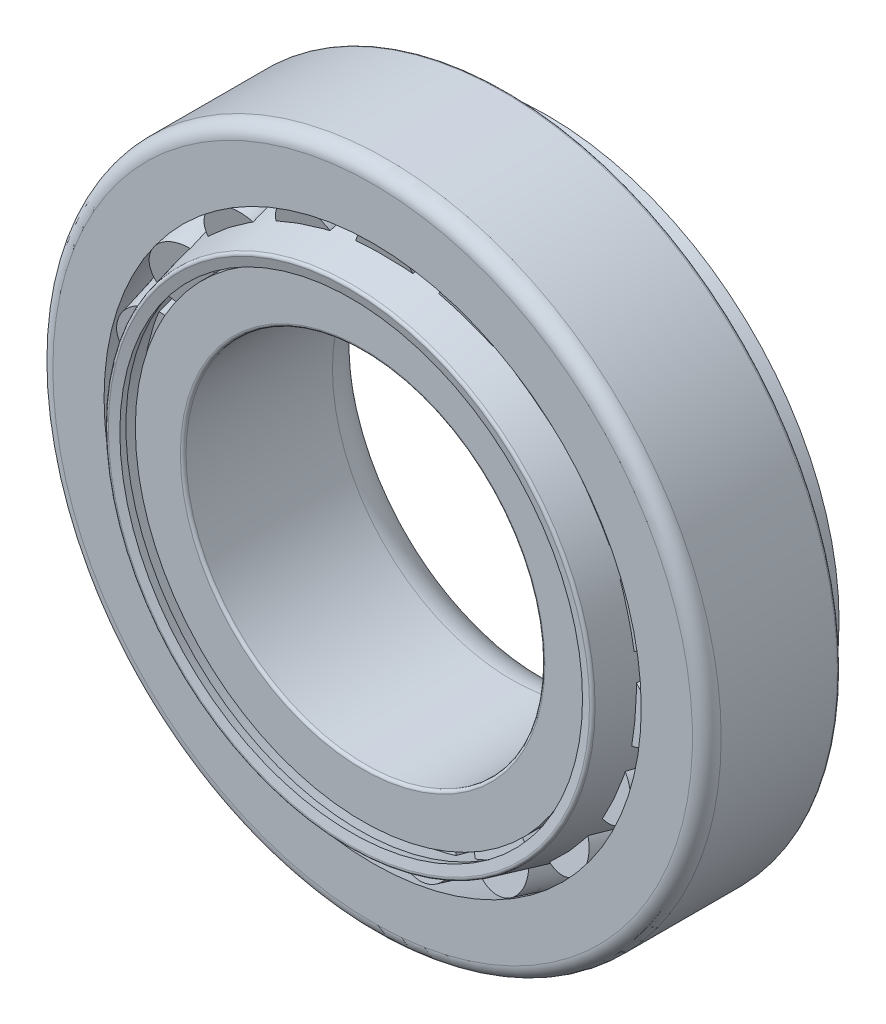
from build123d import *

# Parameters (mm, degrees)
CIRPATTERN1_COUNT = 19
FILLET1_R         = 3.556
FILLET2_R         = 1.27
FILLET3_R         = 0.254
FILLET4_R         = 0.254
FILLET5_R         = 0.254


with BuildPart() as part:
    # Sketch2 → Revolve1 (revolve)
    with BuildSketch(Plane(origin=(0, 0, 0), x_dir=(0, 0, -1), z_dir=(1, 0, 0))):
        Polygon((-5.9055, 29.5671875), (-5.9055, 23.765), (5.9055, 27.015), (5.9055, 29.5671875), align=None)
    revolve(axis=Axis((0, 0, 0), (0, 0, -1)))

    # Fillet2
    fillet2_edges = [part.edges().sort_by_distance(p)[0] for p in [
        (0, -29.5671875, 5.9055),
    ]]
    fillet(fillet2_edges, radius=FILLET2_R)

    # Fillet4
    fillet4_edges = [part.edges().sort_by_distance(p)[0] for p in [
        (0, -29.5671875, -5.9055),
    ]]
    fillet(fillet4_edges, radius=FILLET4_R)


with BuildPart() as body_2:
    # Sketch3 → Revolve2 (revolve)
    with BuildSketch(Plane(origin=(0, 0, 0), x_dir=(0, 0, -1), z_dir=(1, 0, 0))):
        Polygon((-6.7945, 20.11), (-6.7945, 15.875), (9.9695, 15.875), (9.9695, 22.59), (6.332558027, 22.59), (6.706097905, 21.056484436), (-4.038892795, 18.773679177), (-4.364399187, 20.11), align=None)
    revolve(axis=Axis((0, 0, 0), (0, 0, -1)))

    # Fillet1
    fillet1_edges = [body_2.edges().sort_by_distance(p)[0] for p in [
        (0, -15.875, -9.9695),
    ]]
    fillet(fillet1_edges, radius=FILLET1_R)

    # Fillet3
    fillet3_edges = [body_2.edges().sort_by_distance(p)[0] for p in [
        (0, -15.875, 6.7945),
    ]]
    fillet(fillet3_edges, radius=FILLET3_R)


with BuildPart() as body_3:
    # Sketch4 → Revolve3 (revolve)
    with BuildSketch(Plane(origin=(0, 0, 0), x_dir=(0, 0, -1), z_dir=(1, 0, 0))):
        Polygon((9.7155, 25.113969057), (9.542735161, 25.823230864), (-8.0645, 21.534389832), (-7.805352742, 20.470497121), (-7.096090935, 20.64326196), (-7.182473355, 20.997892863), align=None)
    revolve(axis=Axis((0, 0, 0), (0, 0, -1)))

    # Fillet5
    fillet5_edges = [body_3.edges().sort_by_distance(p)[0] for p in [
        (0, -21.534389832, 8.0645),
    ]]
    fillet(fillet5_edges, radius=FILLET5_R)


with BuildPart() as body_4:
    # Sketch6 → Revolve4 (revolve)
    with BuildSketch(Plane(origin=(0, 0, 0), x_dir=(0, 0, -1), z_dir=(1, 0, 0))):
        Polygon((6.706097905, 21.056484436), (6.000838701, 23.951827155), (-4.667236146, 21.353254652), (-4.038892795, 18.773679177), align=None)
    revolve(axis=Axis((0, 21.353254652, 4.667236146), (0, 0.236664162, -0.971591516)))


with BuildPart() as cirpattern1_1:
    # CirPattern1: pattern copy
    add(body_4.part.rotate(Axis((0, 0, 0), (0, 0, 1)), 1 * 360 / CIRPATTERN1_COUNT))


with BuildPart() as cirpattern1_2:
    # CirPattern1: pattern copy
    add(body_4.part.rotate(Axis((0, 0, 0), (0, 0, 1)), 2 * 360 / CIRPATTERN1_COUNT))


with BuildPart() as cirpattern1_3:
    # CirPattern1: pattern copy
    add(body_4.part.rotate(Axis((0, 0, 0), (0, 0, 1)), 3 * 360 / CIRPATTERN1_COUNT))


with BuildPart() as cirpattern1_4:
    # CirPattern1: pattern copy
    add(body_4.part.rotate(Axis((0, 0, 0), (0, 0, 1)), 4 * 360 / CIRPATTERN1_COUNT))


with BuildPart() as cirpattern1_5:
    # CirPattern1: pattern copy
    add(body_4.part.rotate(Axis((0, 0, 0), (0, 0, 1)), 5 * 360 / CIRPATTERN1_COUNT))


with BuildPart() as cirpattern1_6:
    # CirPattern1: pattern copy
    add(body_4.part.rotate(Axis((0, 0, 0), (0, 0, 1)), 6 * 360 / CIRPATTERN1_COUNT))


with BuildPart() as cirpattern1_7:
    # CirPattern1: pattern copy
    add(body_4.part.rotate(Axis((0, 0, 0), (0, 0, 1)), 7 * 360 / CIRPATTERN1_COUNT))


with BuildPart() as cirpattern1_8:
    # CirPattern1: pattern copy
    add(body_4.part.rotate(Axis((0, 0, 0), (0, 0, 1)), 8 * 360 / CIRPATTERN1_COUNT))


with BuildPart() as cirpattern1_9:
    # CirPattern1: pattern copy
    add(body_4.part.rotate(Axis((0, 0, 0), (0, 0, 1)), 9 * 360 / CIRPATTERN1_COUNT))


with BuildPart() as cirpattern1_10:
    # CirPattern1: pattern copy
    add(body_4.part.rotate(Axis((0, 0, 0), (0, 0, 1)), 10 * 360 / CIRPATTERN1_COUNT))


with BuildPart() as cirpattern1_11:
    # CirPattern1: pattern copy
    add(body_4.part.rotate(Axis((0, 0, 0), (0, 0, 1)), 11 * 360 / CIRPATTERN1_COUNT))


with BuildPart() as cirpattern1_12:
    # CirPattern1: pattern copy
    add(body_4.part.rotate(Axis((0, 0, 0), (0, 0, 1)), 12 * 360 / CIRPATTERN1_COUNT))


with BuildPart() as cirpattern1_13:
    # CirPattern1: pattern copy
    add(body_4.part.rotate(Axis((0, 0, 0), (0, 0, 1)), 13 * 360 / CIRPATTERN1_COUNT))


with BuildPart() as cirpattern1_14:
    # CirPattern1: pattern copy
    add(body_4.part.rotate(Axis((0, 0, 0), (0, 0, 1)), 14 * 360 / CIRPATTERN1_COUNT))


with BuildPart() as cirpattern1_15:
    # CirPattern1: pattern copy
    add(body_4.part.rotate(Axis((0, 0, 0), (0, 0, 1)), 15 * 360 / CIRPATTERN1_COUNT))


with BuildPart() as cirpattern1_16:
    # CirPattern1: pattern copy
    add(body_4.part.rotate(Axis((0, 0, 0), (0, 0, 1)), 16 * 360 / CIRPATTERN1_COUNT))


with BuildPart() as cirpattern1_17:
    # CirPattern1: pattern copy
    add(body_4.part.rotate(Axis((0, 0, 0), (0, 0, 1)), 17 * 360 / CIRPATTERN1_COUNT))


with BuildPart() as cirpattern1_18:
    # CirPattern1: pattern copy
    add(body_4.part.rotate(Axis((0, 0, 0), (0, 0, 1)), 18 * 360 / CIRPATTERN1_COUNT))


solid = Compound([part.part, body_2.part, body_3.part, body_4.part, cirpattern1_1.part, cirpattern1_2.part, cirpattern1_3.part, cirpattern1_4.part, cirpattern1_5.part, cirpattern1_6.part, cirpattern1_7.part, cirpattern1_8.part, cirpattern1_9.part, cirpattern1_10.part, cirpattern1_11.part, cirpattern1_12.part, cirpattern1_13.part, cirpattern1_14.part, cirpattern1_15.part, cirpattern1_16.part, cirpattern1_17.part, cirpattern1_18.part])
